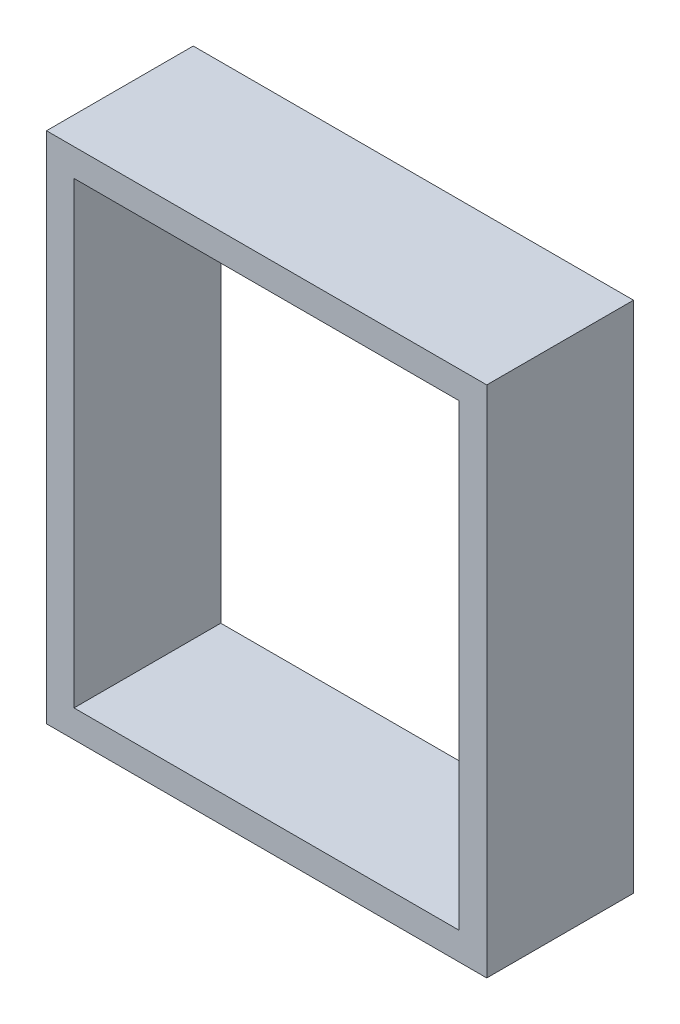
from build123d import *

# Parameters (mm, degrees)
SKETCH1_W           = 76.2
SKETCH1_H           = 88.9
SKETCH1_W_2         = 66.675
SKETCH1_H_2         = 79.375
BOSS_EXTRUDE1_DEPTH = 25.4


with BuildPart() as part:
    # Sketch1 → Boss-Extrude1 (new body)
    with BuildSketch(Plane.XY):
        Rectangle(SKETCH1_W, SKETCH1_H)
        Rectangle(SKETCH1_W_2, SKETCH1_H_2, mode=Mode.SUBTRACT)
    extrude(amount=BOSS_EXTRUDE1_DEPTH)


solid = part.part
